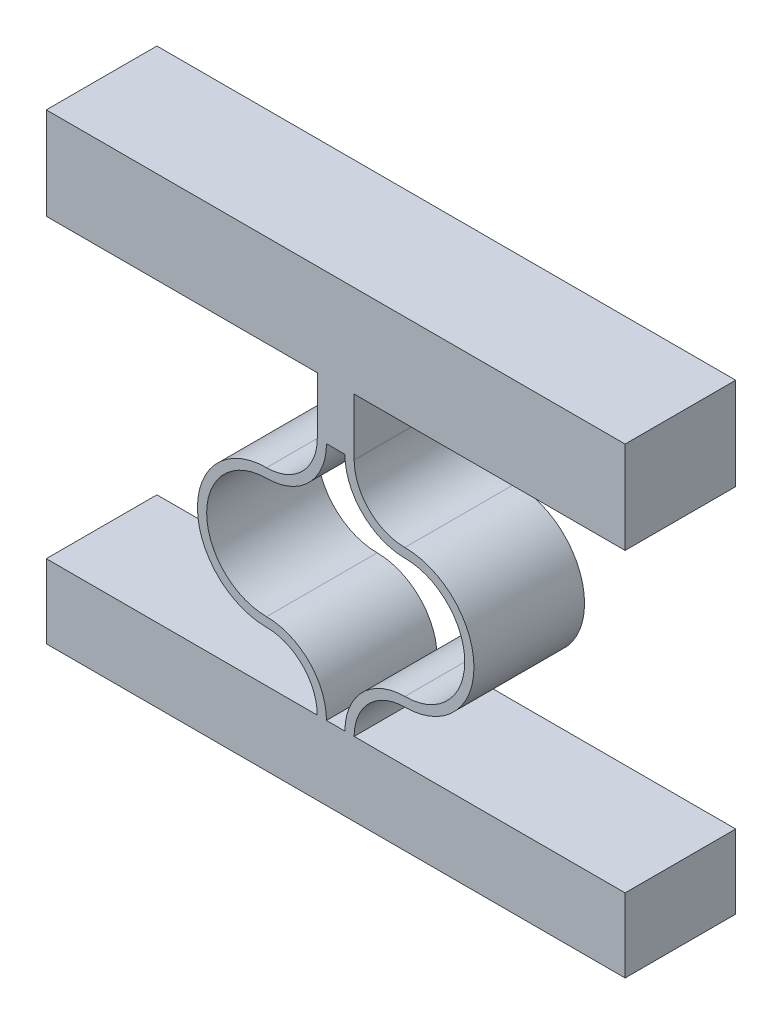
from build123d import *

# Parameters (mm, degrees)
BOSS_EXTRUDE1_DEPTH = 6
SKETCH4_W           = 1.000079602
SKETCH4_H           = 6
BOSS_EXTRUDE2_DEPTH = 0.1
SKETCH7_W           = 6
SKETCH7_H           = 3.085204536
SKETCH7_H_2         = 4
BOSS_EXTRUDE3_DEPTH = 0.5
SKETCH8_W           = 31.399999662
SKETCH8_H           = 5.000000005
BOSS_EXTRUDE4_DEPTH = 6
CUT_EXTRUDE1_DEPTH  = 7.0000001
SKETCH10_W          = 5.000000005
SKETCH10_H          = 12.259999604
CUT_EXTRUDE2_DEPTH  = 7


with BuildPart() as part:
    # Sketch1 → Boss-Extrude1 (new body)
    with BuildSketch(Plane.XY):
        with BuildLine():
            add(Edge.make_bspline(
                [(10.700039975, 14.745204536), (10.770772559, 14.741026808), (11.036928883, 14.722362813), (11.497122592, 14.671037325), (12.289279781, 14.528352814), (13.186428125, 14.281886639), (13.972953946, 14.012479628), (14.659814487, 13.755888369), (15.208666695, 13.545451258), (15.665563716, 13.368818224), (16.123450769, 13.194753096), (16.65208653, 13.002369042), (17.160327646, 12.828079612), (17.673887847, 12.669729106), (18.193716878, 12.533320658), (18.599888692, 12.444944264), (18.888931626, 12.391496574), (19.130919694, 12.353423685), (19.325052629, 12.327000657), (19.519580514, 12.304753805), (19.715757224, 12.286804034), (19.909026191, 12.273251391), (20.101721437, 12.264172749), (20.275673832, 12.260758352), (20.359000366, 12.259999604), (20.4, 12.259999604)],
                knots=[0.519813033, 0.519813033, 0.519813033, 0.519813033, 0.519813033, 0.531036625, 0.562073255, 0.593109869, 0.647173692, 0.678210339, 0.693728663, 0.709246987, 0.740283631, 0.755801952, 0.771320274, 0.79835218, 0.825384086, 0.84090241, 0.856420734, 0.86417989, 0.871939045, 0.8796982, 0.887457356, 0.89521651, 0.902975665, 0.910734819, 0.918493974, 0.918493974, 0.918493974, 0.918493974, 0.918493974], degree=4))
            Line((10.700039975, 14.745204536), (10.700039975, 15.985204536))
            Line((10.700039975, 15.985204536), (9.699960373, 15.985204536))
            Line((9.699960373, 15.985204536), (9.699960373, 14.745204536))
            add(Edge.make_bspline(
                [(0, 12.259999604), (0.040999634, 12.259999604), (0.124259479, 12.260758348), (0.355363371, 12.265310827), (0.583318983, 12.278545215), (0.832717182, 12.299192103), (1.123166493, 12.332562429), (1.414830156, 12.374284724), (1.752116289, 12.434526897), (2.206359313, 12.533321163), (2.726048123, 12.669728195), (3.239713703, 12.828081076), (3.7478924, 13.002367086), (4.184493287, 13.161250769), (4.551277809, 13.299188315), (4.917195343, 13.439475144), (5.282809261, 13.580521779), (5.740185056, 13.755889696), (6.427046416, 14.012478612), (7.213571652, 14.281887279), (8.110720324, 14.528352483), (8.902877469, 14.671037458), (9.363071278, 14.722362846), (9.629227699, 14.741026811), (9.699960373, 14.745204536)],
                knots=[0.081506026, 0.081506026, 0.081506026, 0.081506026, 0.081506026, 0.089265181, 0.097024335, 0.112542644, 0.1203018, 0.128060955, 0.143579266, 0.15909759, 0.174615914, 0.20164782, 0.228679726, 0.244198048, 0.259716369, 0.275234691, 0.290753013, 0.306271337, 0.321789661, 0.352826308, 0.406890131, 0.437926745, 0.468963375, 0.480186981, 0.480186981, 0.480186981, 0.480186981, 0.480186981], degree=4))
            Line((0, 12.259999604), (-5.000000005, 12.259999604))
            Line((-5.000000005, 12.259999604), (-5.000000005, -4))
            Line((-5.000000005, -4), (25.400000005, -4))
            Line((25.400000005, -4), (25.400000005, 12.259999604))
            Line((25.400000005, 12.259999604), (20.4, 12.259999604))
        make_face()
        with BuildLine():
            Line((9.699960373, 14.485204536), (9.699960373, 13.245204536))
            add(Edge.make_bspline(
                [(0, 10.759999604), (0.040999634, 10.759999604), (0.124259479, 10.760758348), (0.355363371, 10.765310827), (0.583318983, 10.778545215), (0.832717182, 10.799192103), (1.123166493, 10.832562429), (1.414830156, 10.874284724), (1.752116289, 10.934526897), (2.206359313, 11.033321163), (2.726048123, 11.169728195), (3.239713703, 11.328081076), (3.7478924, 11.502367086), (4.184493287, 11.661250769), (4.551277809, 11.799188315), (4.917195343, 11.939475144), (5.282809261, 12.080521779), (5.740185056, 12.255889696), (6.427046416, 12.512478612), (7.213571652, 12.781887279), (8.110720324, 13.028352483), (8.902877469, 13.171037458), (9.363071278, 13.222362846), (9.629227699, 13.241026811), (9.699960373, 13.245204536)],
                knots=[0.081506026, 0.081506026, 0.081506026, 0.081506026, 0.081506026, 0.089265181, 0.097024335, 0.112542644, 0.1203018, 0.128060955, 0.143579266, 0.15909759, 0.174615914, 0.20164782, 0.228679726, 0.244198048, 0.259716369, 0.275234691, 0.290753013, 0.306271337, 0.321789661, 0.352826308, 0.406890131, 0.437926745, 0.468963375, 0.480186981, 0.480186981, 0.480186981, 0.480186981, 0.480186981], degree=4))
            Line((0, 10.759999604), (0, 11.999999604))
            add(Edge.make_bspline(
                [(0, 11.999999604), (0.040999634, 11.999999604), (0.124259479, 12.000758348), (0.355363371, 12.005310827), (0.583318983, 12.018545215), (0.832717182, 12.039192103), (1.123166493, 12.072562429), (1.414830156, 12.114284724), (1.752116289, 12.174526897), (2.206359313, 12.273321163), (2.726048123, 12.409728195), (3.239713703, 12.568081076), (3.7478924, 12.742367086), (4.184493287, 12.901250769), (4.551277809, 13.039188315), (4.917195343, 13.179475144), (5.282809261, 13.320521779), (5.740185056, 13.495889696), (6.427046416, 13.752478612), (7.213571652, 14.021887279), (8.110720324, 14.268352483), (8.902877469, 14.411037458), (9.363071278, 14.462362846), (9.629227699, 14.481026811), (9.699960373, 14.485204536)],
                knots=[0.081506026, 0.081506026, 0.081506026, 0.081506026, 0.081506026, 0.089265181, 0.097024335, 0.112542644, 0.1203018, 0.128060955, 0.143579266, 0.15909759, 0.174615914, 0.20164782, 0.228679726, 0.244198048, 0.259716369, 0.275234691, 0.290753013, 0.306271337, 0.321789661, 0.352826308, 0.406890131, 0.437926745, 0.468963375, 0.480186981, 0.480186981, 0.480186981, 0.480186981, 0.480186981], degree=4))
        make_face(mode=Mode.SUBTRACT)
        with BuildLine():
            Line((10.700039975, 13.245204536), (10.700039975, 14.485204536))
            add(Edge.make_bspline(
                [(10.700039975, 14.485204536), (10.770772559, 14.481026808), (11.036928883, 14.462362813), (11.497122592, 14.411037325), (12.289279781, 14.268352814), (13.186428125, 14.021886639), (13.972953947, 13.752479628), (14.659814487, 13.495888369), (15.208666695, 13.285451258), (15.665563716, 13.108818224), (16.123450769, 12.934753096), (16.65208653, 12.742369042), (17.160327646, 12.568079612), (17.673887847, 12.409729106), (18.193716878, 12.273320658), (18.599888692, 12.184944264), (18.888931626, 12.131496574), (19.130919694, 12.093423685), (19.325052629, 12.067000657), (19.519580514, 12.044753805), (19.715757224, 12.026804034), (19.909026191, 12.013251391), (20.101721437, 12.004172749), (20.275673832, 12.000758352), (20.359000366, 11.999999604), (20.4, 11.999999604)],
                knots=[0.519813033, 0.519813033, 0.519813033, 0.519813033, 0.519813033, 0.531036625, 0.562073255, 0.593109869, 0.647173692, 0.678210339, 0.693728663, 0.709246987, 0.740283631, 0.755801952, 0.771320274, 0.79835218, 0.825384086, 0.84090241, 0.856420734, 0.86417989, 0.871939045, 0.8796982, 0.887457356, 0.89521651, 0.902975665, 0.910734819, 0.918493974, 0.918493974, 0.918493974, 0.918493974, 0.918493974], degree=4))
            Line((20.4, 11.999999604), (20.4, 10.759999604))
            add(Edge.make_bspline(
                [(10.700039975, 13.245204536), (10.770772559, 13.241026808), (11.036928883, 13.222362813), (11.497122592, 13.171037325), (12.289279781, 13.028352814), (13.186428125, 12.781886639), (13.972953947, 12.512479628), (14.659814487, 12.255888369), (15.208666695, 12.045451258), (15.665563716, 11.868818224), (16.123450769, 11.694753096), (16.65208653, 11.502369042), (17.160327646, 11.328079612), (17.673887847, 11.169729106), (18.193716878, 11.033320658), (18.599888692, 10.944944264), (18.888931626, 10.891496574), (19.130919694, 10.853423685), (19.325052629, 10.827000657), (19.519580514, 10.804753805), (19.715757224, 10.786804034), (19.909026191, 10.773251391), (20.101721437, 10.764172749), (20.275673832, 10.760758352), (20.359000366, 10.759999604), (20.4, 10.759999604)],
                knots=[0.519813033, 0.519813033, 0.519813033, 0.519813033, 0.519813033, 0.531036625, 0.562073255, 0.593109869, 0.647173692, 0.678210339, 0.693728663, 0.709246987, 0.740283631, 0.755801952, 0.771320274, 0.79835218, 0.825384086, 0.84090241, 0.856420734, 0.86417989, 0.871939045, 0.8796982, 0.887457356, 0.89521651, 0.902975665, 0.910734819, 0.918493974, 0.918493974, 0.918493974, 0.918493974, 0.918493974], degree=4))
        make_face(mode=Mode.SUBTRACT)
        with BuildLine():
            Line((0, 0), (0, 10.499999604))
            add(Edge.make_bspline(
                [(0, 10.499999604), (0.040999634, 10.499999604), (0.124259479, 10.500758348), (0.355363371, 10.505310827), (0.583318983, 10.518545215), (0.832717182, 10.539192103), (1.123166493, 10.572562429), (1.414830156, 10.614284724), (1.752116289, 10.674526897), (2.206359313, 10.773321163), (2.726048123, 10.909728195), (3.239713703, 11.068081076), (3.7478924, 11.242367086), (4.184493287, 11.401250769), (4.551277809, 11.539188315), (4.917195343, 11.679475144), (5.282809261, 11.820521779), (5.740185056, 11.995889696), (6.427046416, 12.252478612), (7.213571652, 12.521887279), (8.110720324, 12.768352483), (8.902877469, 12.911037458), (9.363071278, 12.962362846), (9.629227699, 12.981026811), (9.699960373, 12.985204536)],
                knots=[0.081506026, 0.081506026, 0.081506026, 0.081506026, 0.081506026, 0.089265181, 0.097024335, 0.112542644, 0.1203018, 0.128060955, 0.143579266, 0.15909759, 0.174615914, 0.20164782, 0.228679726, 0.244198048, 0.259716369, 0.275234691, 0.290753013, 0.306271337, 0.321789661, 0.352826308, 0.406890131, 0.437926745, 0.468963375, 0.480186981, 0.480186981, 0.480186981, 0.480186981, 0.480186981], degree=4))
            ThreePointArc((9.699960373, 12.985204536), (8.889305781, 11.050232382), (6.950000174, 10.25))
            ThreePointArc((6.950000174, 10.25), (3.200000174, 6.5), (6.950000174, 2.75))
            ThreePointArc((6.950000174, 2.75), (8.894543822, 1.944543648), (9.700000174, 0))
            Line((9.700000174, 0), (0, 0))
        make_face(mode=Mode.SUBTRACT)
        with BuildLine():
            ThreePointArc((6.950000174, 9.75), (9.248097213, 10.701902961), (10.200000174, 13))
            ThreePointArc((10.200000174, 13), (11.151903135, 10.701902961), (13.450000174, 9.75))
            ThreePointArc((13.450000174, 9.75), (16.700000174, 6.5), (13.450000174, 3.25))
            ThreePointArc((13.450000174, 3.25), (11.151903135, 2.298097039), (10.200000174, 0))
            ThreePointArc((10.200000174, 0), (9.248097213, 2.298097039), (6.950000174, 3.25))
            ThreePointArc((6.950000174, 3.25), (3.700000174, 6.5), (6.950000174, 9.75))
        make_face(mode=Mode.SUBTRACT)
        with BuildLine():
            ThreePointArc((13.450000174, 10.25), (11.510694567, 11.050232382), (10.700039975, 12.985204536))
            add(Edge.make_bspline(
                [(10.700039975, 12.985204536), (10.770772559, 12.981026808), (11.036928883, 12.962362813), (11.497122592, 12.911037325), (12.289279781, 12.768352814), (13.186428125, 12.521886639), (13.972953947, 12.252479628), (14.659814487, 11.995888369), (15.208666695, 11.785451258), (15.665563716, 11.608818224), (16.123450769, 11.434753096), (16.65208653, 11.242369042), (17.160327646, 11.068079612), (17.673887847, 10.909729106), (18.193716878, 10.773320658), (18.599888692, 10.684944264), (18.888931626, 10.631496574), (19.130919694, 10.593423685), (19.325052629, 10.567000657), (19.519580514, 10.544753805), (19.715757224, 10.526804034), (19.909026191, 10.513251391), (20.101721437, 10.504172749), (20.275673832, 10.500758352), (20.359000366, 10.499999604), (20.4, 10.499999604)],
                knots=[0.519813033, 0.519813033, 0.519813033, 0.519813033, 0.519813033, 0.531036625, 0.562073255, 0.593109869, 0.647173692, 0.678210339, 0.693728663, 0.709246987, 0.740283631, 0.755801952, 0.771320274, 0.79835218, 0.825384086, 0.84090241, 0.856420734, 0.86417989, 0.871939045, 0.8796982, 0.887457356, 0.89521651, 0.902975665, 0.910734819, 0.918493974, 0.918493974, 0.918493974, 0.918493974, 0.918493974], degree=4))
            Line((20.4, 10.499999604), (20.4, 0))
            Line((20.4, 0), (10.700000174, 0))
            ThreePointArc((10.700000174, 0), (11.505456526, 1.944543648), (13.450000174, 2.75))
            ThreePointArc((13.450000174, 2.75), (17.200000174, 6.5), (13.450000174, 10.25))
        make_face(mode=Mode.SUBTRACT)
    extrude(amount=BOSS_EXTRUDE1_DEPTH)

    # Sketch4 → Boss-Extrude2 (add)
    with BuildSketch(Plane(origin=(0, 15.985204536, 0), x_dir=(1, 0, 0), z_dir=(0, 1, 0))):
        with Locations((10.200000174, -3)):
            Rectangle(SKETCH4_W, SKETCH4_H)
    extrude(amount=BOSS_EXTRUDE2_DEPTH)

    # Split2
    split(bisect_by=Plane(origin=(10.200000174, 0, 0), x_dir=(0, -1, 0), z_dir=(-1, 0, 0)), keep=Keep.BOTTOM)

    # Sketch7 → Boss-Extrude3 (add)
    with BuildSketch(Plane.ZY.offset(-10.200000174)):
        with Locations((3, 14.542602268)):
            Rectangle(SKETCH7_W, SKETCH7_H)
        with Locations((3, -2)):
            Rectangle(SKETCH7_W, SKETCH7_H_2)
    extrude(amount=BOSS_EXTRUDE3_DEPTH)

    # Mirror2: part across plane


with BuildPart() as part_1:
    add(part.part)
    add(part.part.mirror(Plane.ZY.offset(-9.700000174)))

    # Sketch8 → Boss-Extrude4 (add)
    with BuildSketch(Plane.XY.offset(6)):
        with Locations((9.700000174, 18.585204539)):
            Rectangle(SKETCH8_W, SKETCH8_H)
    extrude(amount=-BOSS_EXTRUDE4_DEPTH)

    # Sketch9 → Cut-Extrude1 (cut, through all)
    with BuildSketch(Plane.XY.offset(6)):
        with BuildLine():
            Line((-0.999999652, 10.499999604), (-0.999999652, 12.259999604))
            add(Edge.make_bspline(
                [(8.699960373, 14.745204536), (8.629227789, 14.741026808), (8.363071465, 14.722362813), (7.902877756, 14.671037325), (7.110720568, 14.528352814), (6.213572223, 14.281886639), (5.427046402, 14.012479628), (4.740185861, 13.755888369), (4.191333653, 13.545451258), (3.734436632, 13.368818224), (3.276549579, 13.194753096), (2.747913818, 13.002369042), (2.239672702, 12.828079612), (1.726112501, 12.669729106), (1.20628347, 12.533320658), (0.800111657, 12.444944264), (0.511068722, 12.391496574), (0.269080654, 12.353423685), (0.074947719, 12.327000657), (-0.119580166, 12.304753805), (-0.315756876, 12.286804034), (-0.509025843, 12.273251391), (-0.701721089, 12.264172749), (-0.875673484, 12.260758352), (-0.959000018, 12.259999604), (-0.999999652, 12.259999604)],
                knots=[0.519813033, 0.519813033, 0.519813033, 0.519813033, 0.519813033, 0.531036625, 0.562073255, 0.593109869, 0.647173692, 0.678210339, 0.693728663, 0.709246987, 0.740283631, 0.755801952, 0.771320274, 0.79835218, 0.825384086, 0.84090241, 0.856420734, 0.86417989, 0.871939045, 0.8796982, 0.887457356, 0.89521651, 0.902975665, 0.910734819, 0.918493974, 0.918493974, 0.918493974, 0.918493974, 0.918493974], degree=4))
            Line((8.699960373, 14.745204536), (8.699960373, 12.985204536))
            add(Edge.make_bspline(
                [(8.699960373, 12.985204536), (8.629227789, 12.981026808), (8.363071465, 12.962362813), (7.902877756, 12.911037325), (7.110720568, 12.768352814), (6.213572223, 12.521886639), (5.427046402, 12.252479628), (4.740185861, 11.995888369), (4.191333653, 11.785451258), (3.734436632, 11.608818224), (3.276549579, 11.434753096), (2.747913818, 11.242369042), (2.239672702, 11.068079612), (1.726112501, 10.909729106), (1.20628347, 10.773320658), (0.800111657, 10.684944264), (0.511068722, 10.631496574), (0.269080654, 10.593423685), (0.074947719, 10.567000657), (-0.119580166, 10.544753805), (-0.315756876, 10.526804034), (-0.509025843, 10.513251391), (-0.701721089, 10.504172749), (-0.875673484, 10.500758352), (-0.959000018, 10.499999604), (-0.999999652, 10.499999604)],
                knots=[0.519813033, 0.519813033, 0.519813033, 0.519813033, 0.519813033, 0.531036625, 0.562073255, 0.593109869, 0.647173692, 0.678210339, 0.693728663, 0.709246987, 0.740283631, 0.755801952, 0.771320274, 0.79835218, 0.825384086, 0.84090241, 0.856420734, 0.86417989, 0.871939045, 0.8796982, 0.887457356, 0.89521651, 0.902975665, 0.910734819, 0.918493974, 0.918493974, 0.918493974, 0.918493974, 0.918493974], degree=4))
        make_face()
        with BuildLine():
            Line((20.4, 10.499999604), (20.4, 12.259999604))
            add(Edge.make_bspline(
                [(10.700039975, 14.745204536), (10.770772559, 14.741026808), (11.036928883, 14.722362813), (11.497122592, 14.671037325), (12.289279781, 14.528352814), (13.186428125, 14.281886639), (13.972953946, 14.012479628), (14.659814487, 13.755888369), (15.208666695, 13.545451258), (15.665563716, 13.368818224), (16.123450769, 13.194753096), (16.65208653, 13.002369042), (17.160327646, 12.828079612), (17.673887847, 12.669729106), (18.193716878, 12.533320658), (18.599888692, 12.444944264), (18.888931626, 12.391496574), (19.130919694, 12.353423685), (19.325052629, 12.327000657), (19.519580514, 12.304753805), (19.715757224, 12.286804034), (19.909026191, 12.273251391), (20.101721437, 12.264172749), (20.275673832, 12.260758352), (20.359000366, 12.259999604), (20.4, 12.259999604)],
                knots=[0.519813033, 0.519813033, 0.519813033, 0.519813033, 0.519813033, 0.531036625, 0.562073255, 0.593109869, 0.647173692, 0.678210339, 0.693728663, 0.709246987, 0.740283631, 0.755801952, 0.771320274, 0.79835218, 0.825384086, 0.84090241, 0.856420734, 0.86417989, 0.871939045, 0.8796982, 0.887457356, 0.89521651, 0.902975665, 0.910734819, 0.918493974, 0.918493974, 0.918493974, 0.918493974, 0.918493974], degree=4))
            Line((10.700039975, 14.745204536), (10.700039975, 12.985204536))
            add(Edge.make_bspline(
                [(10.700039975, 12.985204536), (10.770772559, 12.981026808), (11.036928883, 12.962362813), (11.497122592, 12.911037325), (12.289279781, 12.768352814), (13.186428125, 12.521886639), (13.972953947, 12.252479628), (14.659814487, 11.995888369), (15.208666695, 11.785451258), (15.665563716, 11.608818224), (16.123450769, 11.434753096), (16.65208653, 11.242369042), (17.160327646, 11.068079612), (17.673887847, 10.909729106), (18.193716878, 10.773320658), (18.599888692, 10.684944264), (18.888931626, 10.631496574), (19.130919694, 10.593423685), (19.325052629, 10.567000657), (19.519580514, 10.544753805), (19.715757224, 10.526804034), (19.909026191, 10.513251391), (20.101721437, 10.504172749), (20.275673832, 10.500758352), (20.359000366, 10.499999604), (20.4, 10.499999604)],
                knots=[0.519813033, 0.519813033, 0.519813033, 0.519813033, 0.519813033, 0.531036625, 0.562073255, 0.593109869, 0.647173692, 0.678210339, 0.693728663, 0.709246987, 0.740283631, 0.755801952, 0.771320274, 0.79835218, 0.825384086, 0.84090241, 0.856420734, 0.86417989, 0.871939045, 0.8796982, 0.887457356, 0.89521651, 0.902975665, 0.910734819, 0.918493974, 0.918493974, 0.918493974, 0.918493974, 0.918493974], degree=4))
        make_face()
    extrude(amount=-CUT_EXTRUDE1_DEPTH, mode=Mode.SUBTRACT)

    # Sketch10 → Cut-Extrude2 (cut, through all)
    with BuildSketch(Plane.XY.offset(6)):
        with Locations((-3.499999654, 6.129999802)):
            Rectangle(SKETCH10_W, SKETCH10_H)
        with Locations((22.900000003, 6.129999802)):
            Rectangle(SKETCH10_W, SKETCH10_H)
    extrude(amount=-CUT_EXTRUDE2_DEPTH, mode=Mode.SUBTRACT)


solid = part_1.part
